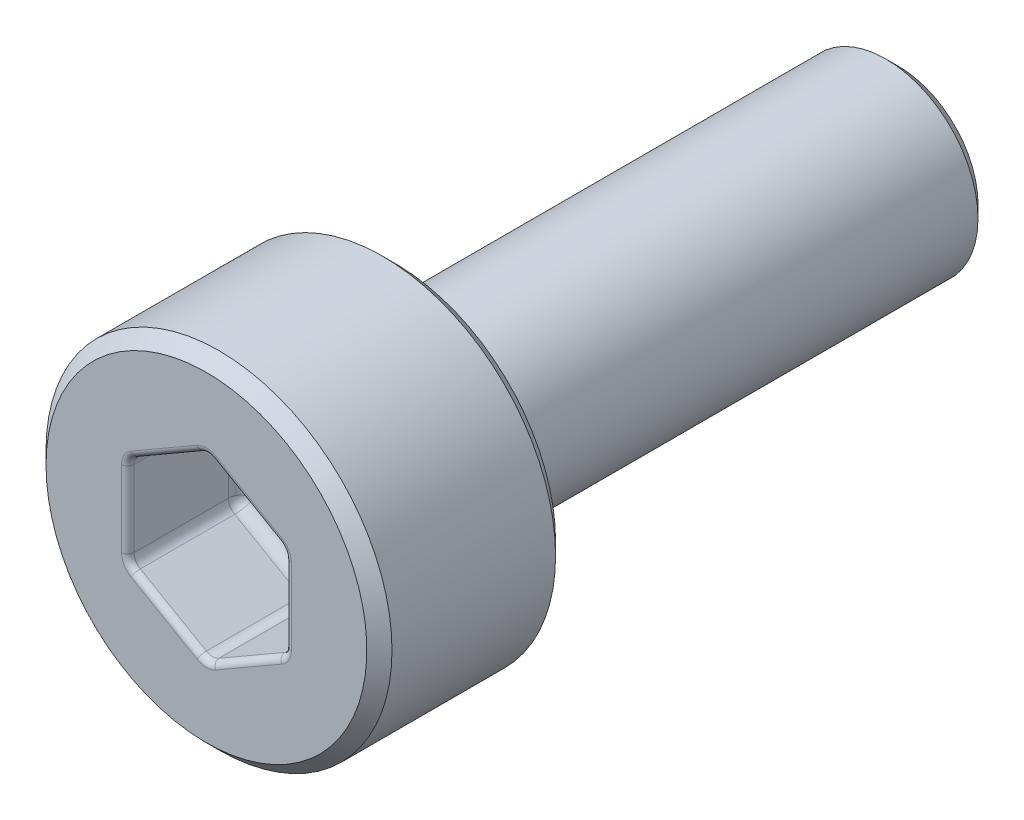
from build123d import *

# Parameters (mm, degrees)
SCHNITT_LINEAR_AUSTRAGEN1_DEPTH = 1.8
FASE1_SIZE                      = 0.2
VERRUNDUNG1_R                   = 0.2
VERRUNDUNG2_R                   = 0.1


with BuildPart() as part:
    # Skizze1 → Rotation1 (revolve)
    with BuildSketch(Plane(origin=(0, 0, 0), x_dir=(0, 0, -1), z_dir=(1, 0, 0))):
        Polygon((-3, 0), (-3, 2.75), (0, 2.75), (0, 1.465), (8, 1.465), (8, 0), align=None)
    revolve(axis=Axis((0, 0, 21.919879518), (0, 0, -1)))

    # Skizze2 → Schnitt-Linear austragen1 (cut)
    with BuildSketch(Plane.XY.offset(3)):
        Polygon((1.25, -0.721687836), (1.25, 0.721687836), (0, 1.443375673), (-1.25, 0.721687836), (-1.25, -0.721687836), (0, -1.443375673), align=None)
    extrude(amount=-SCHNITT_LINEAR_AUSTRAGEN1_DEPTH, mode=Mode.SUBTRACT)

    # Fase1
    fase1_edges = [part.edges().sort_by_distance(p)[0] for p in [
        (0, -2.75, 3),
        (0, -2.75, 0),
        (0, -1.465, -8),
    ]]
    chamfer(fase1_edges, length=FASE1_SIZE)

    # Verrundung1
    verrundung1_edges = [part.edges().sort_by_distance(p)[0] for p in [
        (-0.625, -1.082531755, 1.2),
        (-1.25, 0, 1.2),
        (-0.625, 1.082531755, 1.2),
        (0.625, 1.082531755, 1.2),
        (1.25, 0, 1.2),
        (0.625, -1.082531755, 1.2),
        (-1.25, -0.721687836, 2.1),
        (0, -1.443375673, 2.1),
        (1.25, -0.721687836, 2.1),
        (1.25, 0.721687836, 2.1),
        (0, 1.443375673, 2.1),
        (-1.25, 0.721687836, 2.1),
        (0, -1.465, 0),
    ]]
    fillet(verrundung1_edges, radius=VERRUNDUNG1_R)

    # Verrundung2
    verrundung2_edges = [part.edges().sort_by_distance(p)[0] for p in [
        (1.223205081, -0.706217783, 3),
        (0.625, -1.082531755, 3),
        (0, -1.412435565, 3),
        (-0.625, -1.082531755, 3),
        (-1.223205081, -0.706217783, 3),
        (-1.25, 0, 3),
        (-1.223205081, 0.706217783, 3),
        (-0.625, 1.082531755, 3),
        (0, 1.412435565, 3),
        (0.625, 1.082531755, 3),
        (1.223205081, 0.706217783, 3),
        (1.25, 0, 3),
    ]]
    fillet(verrundung2_edges, radius=VERRUNDUNG2_R)


solid = part.part
